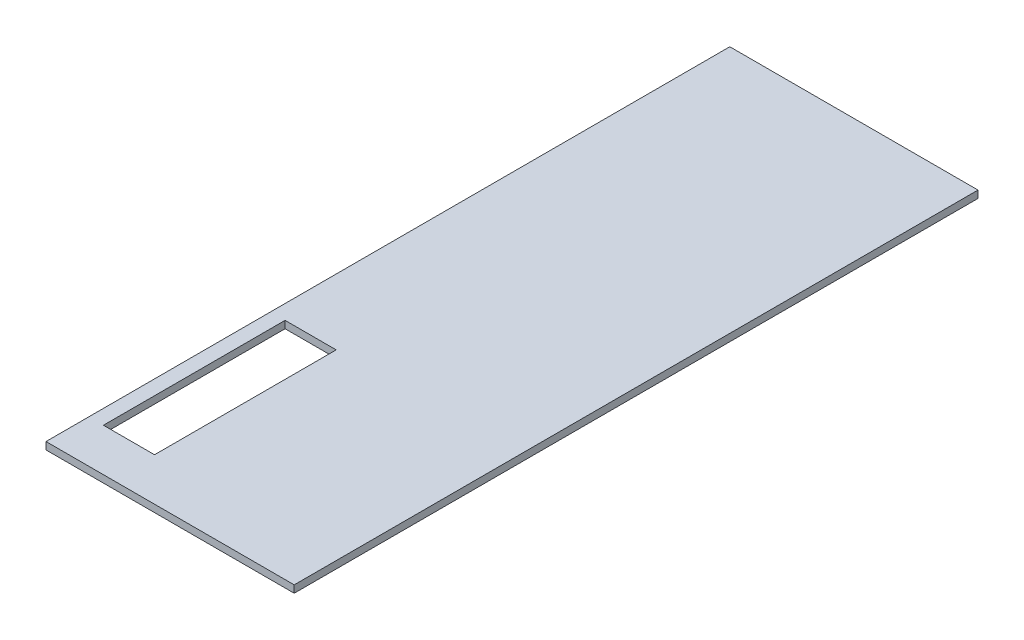
from build123d import *

# Parameters (mm, degrees)
SKETCH_1_W            = 4080
SKETCH_1_H            = 11240
EXTRUDE_1_DEPTH       = 120
SKETCH_2_W            = 840
SKETCH_2_H            = 2985.867704249
CUT_EXTRUDE_646_DEPTH = 121


with BuildPart() as part:
    # 草图1 → 凸台-拉伸1 (new body)
    with BuildSketch(Plane(origin=(0, 0, 0), x_dir=(1, 0, 0), z_dir=(0, 1, 0))):
        Rectangle(SKETCH_1_W, SKETCH_1_H)
    extrude(amount=-EXTRUDE_1_DEPTH)

    # 草图2 → Cut-Extrude 646 (cut, through all)
    with BuildSketch(Plane.XZ.offset(120)):
        with Locations((-1380, 3422.933852124)):
            Rectangle(SKETCH_2_W, SKETCH_2_H)
    extrude(amount=-CUT_EXTRUDE_646_DEPTH, mode=Mode.SUBTRACT)


solid = part.part
